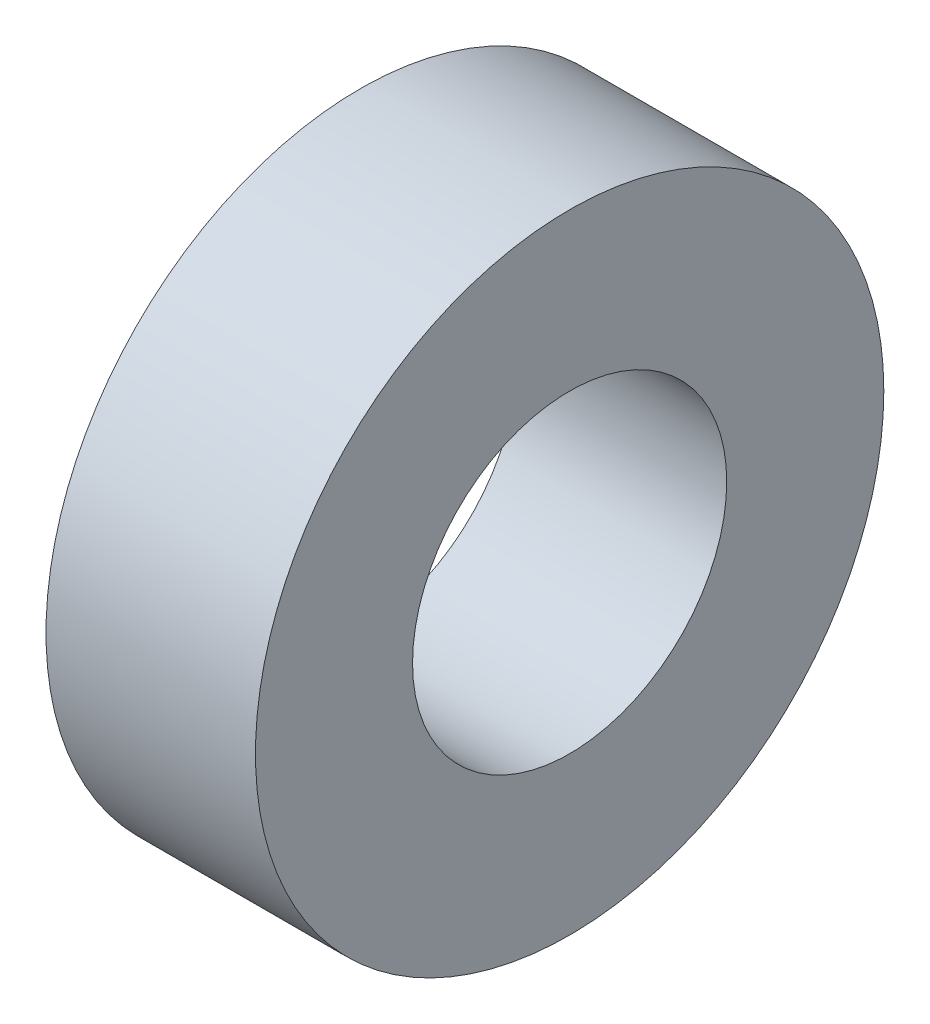
from build123d import *

# Parameters (mm, degrees)
SKETCH_1_R      = 6
SKETCH_1_R_2    = 3
EXTRUDE_1_DEPTH = 4


with BuildPart() as part:
    # 草图1 → 凸台-拉伸1 (new body)
    with BuildSketch(Plane(origin=(0, 0, 0), x_dir=(0, 0, -1), z_dir=(1, 0, 0))):
        Circle(SKETCH_1_R)
        Circle(SKETCH_1_R_2, mode=Mode.SUBTRACT)
    extrude(amount=EXTRUDE_1_DEPTH)


solid = part.part
